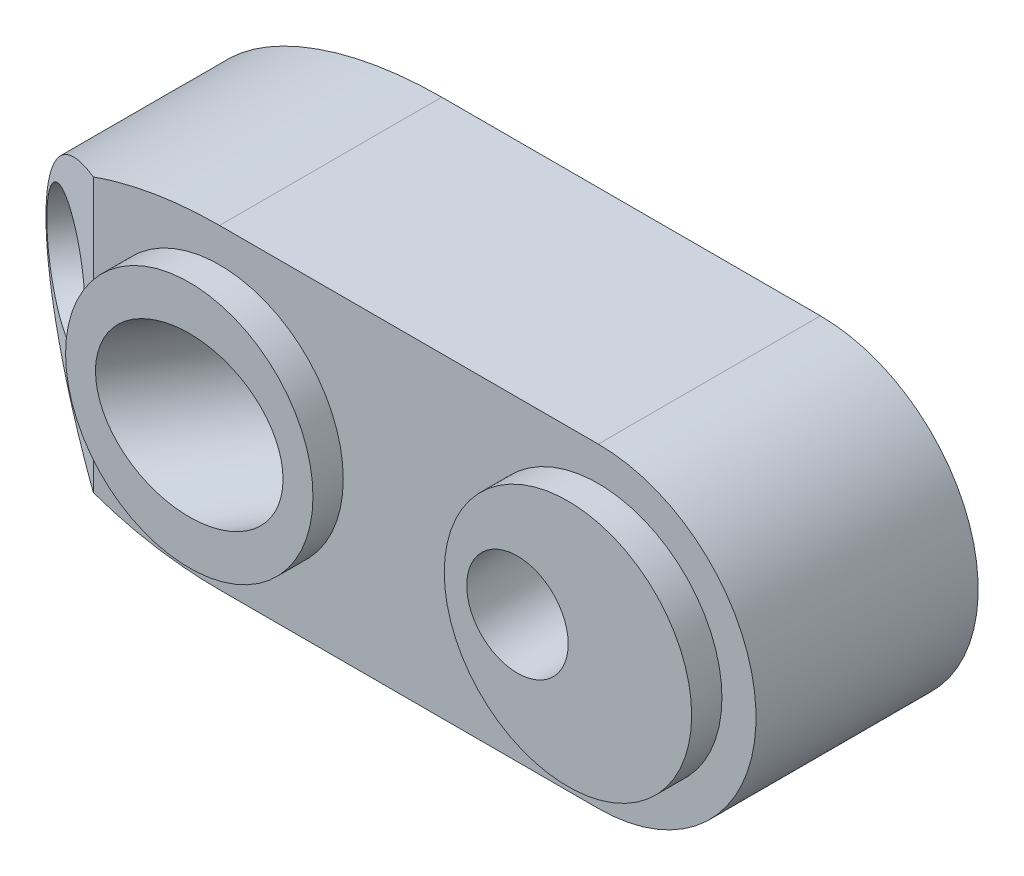
from build123d import *

# Parameters (mm, degrees)
BOSS_EXTRUDE1_DEPTH     = 12.7
SKETCH2_OUTSIDE_W       = 50.606
SKETCH2_OUTSIDE_H       = 26.794
SKETCH2_OUTSIDE_R       = 6.223
CUT_EXTRUDE1_DEPTH      = 1.524
SKETCH3_R               = 4
CUT_EXTRUDE2_DEPTH      = 7.729974744
CUT_EXTRUDE2_DEPTH_BACK = 26.071407102
SKETCH5_W               = 11
SKETCH5_H               = 21
CUT_EXTRUDE3_DEPTH      = 19.721407102
CUT_EXTRUDE4_DEPTH      = 8.9375001
CUT_EXTRUDE4_DEPTH_BACK = 8.9375001
F_1_4_20_TAPPED_HOLE1_D = 5.1054


with BuildPart() as part:
    # Sketch1 → Boss-Extrude1 (new body)
    with BuildSketch(Plane.XY):
        with BuildLine():
            Line((0, 7.9375), (19.05, 7.9375))
            ThreePointArc((19.05, 7.9375), (26.9875, 0), (19.05, -7.9375))
            Line((19.05, -7.9375), (0, -7.9375))
            add(Edge.make_bspline(
                [(0, 7.9375), (-12.7, 7.9375), (-12.7, 0), (-12.7, -7.9375), (0, -7.9375)],
                knots=[4.71238898, 4.71238898, 4.71238898, 6.283185307, 6.283185307, 7.853981634, 7.853981634, 7.853981634], degree=2, weights=[1, 0.707106781, 1, 0.707106781, 1]))
        make_face()
    extrude(amount=-BOSS_EXTRUDE1_DEPTH)

    # Sketch2 outside → Cut-Extrude1 (cut)
    with BuildSketch(Plane.XY):
        with Locations((7.144, 0)):
            Rectangle(SKETCH2_OUTSIDE_W, SKETCH2_OUTSIDE_H)
        Circle(SKETCH2_OUTSIDE_R, mode=Mode.SUBTRACT)
        with Locations((19.05, 0)):
            Circle(SKETCH2_OUTSIDE_R, mode=Mode.SUBTRACT)
    extrude(amount=-CUT_EXTRUDE1_DEPTH, mode=Mode.SUBTRACT)

    # Sketch3 → Cut-Extrude2 (cut, two sides)
    with BuildSketch(Plane(origin=(0, 0, 0), x_dir=(0, -1, 0), z_dir=(-0.529919264, 0, 0.848048096))) as cut_extrude2_sk:
        Circle(SKETCH3_R)
    extrude(amount=CUT_EXTRUDE2_DEPTH, mode=Mode.SUBTRACT)
    extrude(cut_extrude2_sk.sketch, amount=-CUT_EXTRUDE2_DEPTH_BACK, mode=Mode.SUBTRACT)

    # Sketch5 → Cut-Extrude3 (cut, through all)
    with BuildSketch(Plane(origin=(3.364987328, 0, -5.385105411), x_dir=(0, -1, 0), z_dir=(-0.529919264, 0, 0.848048096))):
        with Locations((0, -5)):
            Rectangle(SKETCH5_W, SKETCH5_H)
    extrude(amount=-CUT_EXTRUDE3_DEPTH, mode=Mode.SUBTRACT)

    # Sketch8 → Cut-Extrude4 (cut, two sides)
    with BuildSketch(Plane(origin=(0, 0, 0), x_dir=(1, 0, 0), z_dir=(0, 1, 0))) as cut_extrude4_sk:
        Polygon((-12.7, 5.491920385), (-6.35, 1.524), (-8.133171609, -1.329671097), (-14.483171609, 2.638249288), align=None)
    extrude(amount=CUT_EXTRUDE4_DEPTH, mode=Mode.SUBTRACT)
    extrude(cut_extrude4_sk.sketch, amount=-CUT_EXTRUDE4_DEPTH_BACK, mode=Mode.SUBTRACT)

    # Sketch4 → Cut-Revolve1 (revolve, cut)
    with BuildSketch(Plane(origin=(0, 0, 0), x_dir=(1, 0, 0), z_dir=(0, 1, 0))):
        Polygon((-3.814729231, 13.709496198), (-10.002795555, 3.806519991), (-12.587646152, 5.421713909), (-10.816358141, 8.256367274), (-9.847039167, 7.650669555), (-5.430260854, 14.718992397), align=None)
    revolve(axis=Axis((-10.002795555, 0, -3.806519991), (-0.529919264, 0, 0.848048096)), mode=Mode.SUBTRACT)

    # 1/4-20 Tapped Hole1 (through all)
    with Locations(Plane.XY):
        with Locations((16.51, 0)):
            Hole(F_1_4_20_TAPPED_HOLE1_D / 2)


solid = part.part
